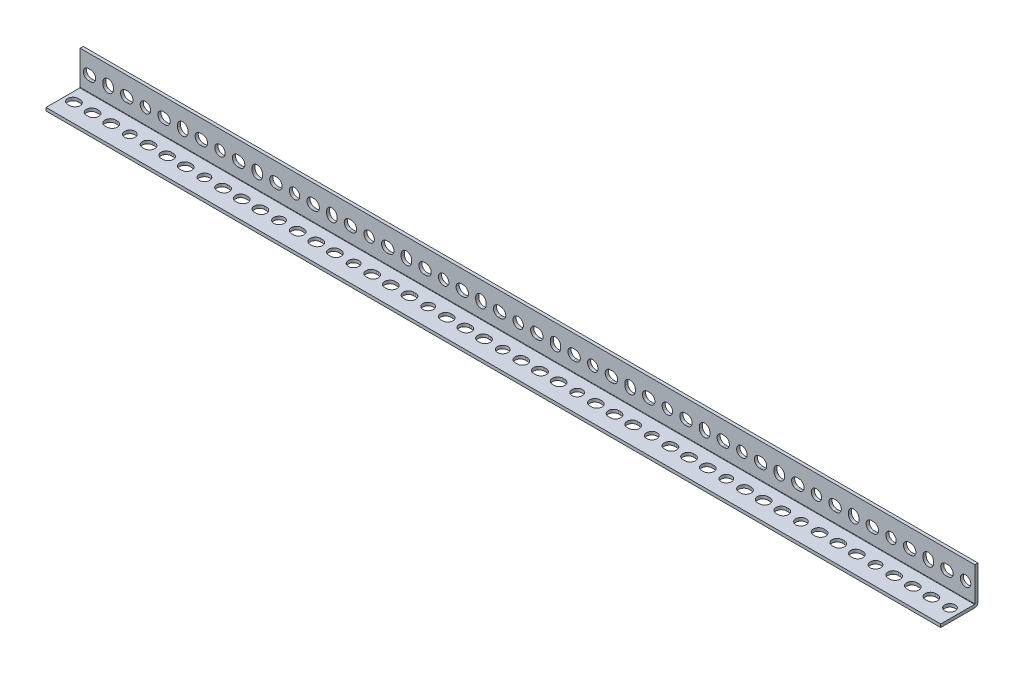
from build123d import *

# Parameters (mm, degrees)
BOSS_EXTRUDE1_DEPTH      = 457.2
BOSS_EXTRUDE1_DEPTH_BACK = 457.2
SKETCH5_R                = 5.334
CUT_EXTRUDE1_DEPTH       = 20.05
LPATTERN1_COUNT          = 13
LPATTERN1_PITCH          = 76.2
SKETCH6_R                = 5.334
CUT_EXTRUDE2_DEPTH       = 20.05
LPATTERN2_COUNT          = 13
LPATTERN2_PITCH          = 76.2


with BuildPart() as part:
    # Sketch4 → Boss-Extrude1 (new body, two sides)
    with BuildSketch(Plane(origin=(0, 0, 0), x_dir=(0, 0, -1), z_dir=(1, 0, 0))) as boss_extrude1_sk:
        with BuildLine():
            Line((-19.05, -15.875), (15.494, -15.875))
            ThreePointArc((15.494, -15.875), (15.763407684, -15.763407684), (15.875, -15.494))
            Line((15.875, -15.494), (15.875, 19.05))
            Line((15.875, 19.05), (19.05, 19.05))
            Line((19.05, 19.05), (19.05, -15.494))
            ThreePointArc((19.05, -15.494), (18.008471714, -18.008471714), (15.494, -19.05))
            Line((15.494, -19.05), (-19.05, -19.05))
            Line((-19.05, -19.05), (-19.05, -15.875))
        make_face()
    extrude(amount=BOSS_EXTRUDE1_DEPTH)
    extrude(boss_extrude1_sk.sketch, amount=-BOSS_EXTRUDE1_DEPTH_BACK)

    # Sketch5 → Cut-Extrude1 (cut, through all)
    with BuildSketch(Plane.XY):
        with Locations((447.675, 0)):
            Circle(SKETCH5_R)
        with BuildLine():
            Line((427.609, 5.334), (429.641, 5.334))
            ThreePointArc((429.641, 5.334), (434.975, 0), (429.641, -5.334))
            Line((429.641, -5.334), (427.609, -5.334))
            ThreePointArc((427.609, -5.334), (422.275, 0), (427.609, 5.334))
        make_face()
        with BuildLine():
            Line((414.909, 1.016), (414.909, -1.016))
            ThreePointArc((414.909, -1.016), (409.575, -6.35), (404.241, -1.016))
            Line((404.241, -1.016), (404.241, 1.016))
            ThreePointArc((404.241, 1.016), (409.575, 6.35), (414.909, 1.016))
        make_face()
        with BuildLine():
            Line((389.509, 5.334), (391.541, 5.334))
            ThreePointArc((391.541, 5.334), (396.875, 0), (391.541, -5.334))
            Line((391.541, -5.334), (389.509, -5.334))
            ThreePointArc((389.509, -5.334), (384.175, 0), (389.509, 5.334))
        make_face()
    cut_extrude1 = extrude(amount=-CUT_EXTRUDE1_DEPTH, mode=Mode.SUBTRACT)

    # LPattern1: Cut-Extrude1 ×13
    with Locations(*[(-i * LPATTERN1_PITCH, 0, 0) for i in range(1, LPATTERN1_COUNT)]):
        add(cut_extrude1, mode=Mode.SUBTRACT)

    # Sketch6 → Cut-Extrude2 (cut, through all)
    with BuildSketch(Plane(origin=(0, 0, 0), x_dir=(1, 0, 0), z_dir=(0, 1, 0))):
        with Locations((447.675, 0)):
            Circle(SKETCH6_R)
        with BuildLine():
            Line((427.609, 5.334), (429.641, 5.334))
            ThreePointArc((429.641, 5.334), (434.975, 0), (429.641, -5.334))
            Line((429.641, -5.334), (427.609, -5.334))
            ThreePointArc((427.609, -5.334), (422.275, 0), (427.609, 5.334))
        make_face()
        with BuildLine():
            Line((389.509, 5.334), (391.541, 5.334))
            ThreePointArc((391.541, 5.334), (396.875, 0), (391.541, -5.334))
            Line((391.541, -5.334), (389.509, -5.334))
            ThreePointArc((389.509, -5.334), (384.175, 0), (389.509, 5.334))
        make_face()
        with BuildLine():
            Line((408.559, 5.334), (410.591, 5.334))
            ThreePointArc((410.591, 5.334), (415.925, 0), (410.591, -5.334))
            Line((410.591, -5.334), (408.559, -5.334))
            ThreePointArc((408.559, -5.334), (403.225, 0), (408.559, 5.334))
        make_face()
    cut_extrude2 = extrude(amount=-CUT_EXTRUDE2_DEPTH, mode=Mode.SUBTRACT)

    # LPattern2: Cut-Extrude2 ×13
    with Locations(*[(-i * LPATTERN2_PITCH, 0, 0) for i in range(1, LPATTERN2_COUNT)]):
        add(cut_extrude2, mode=Mode.SUBTRACT)


solid = part.part
